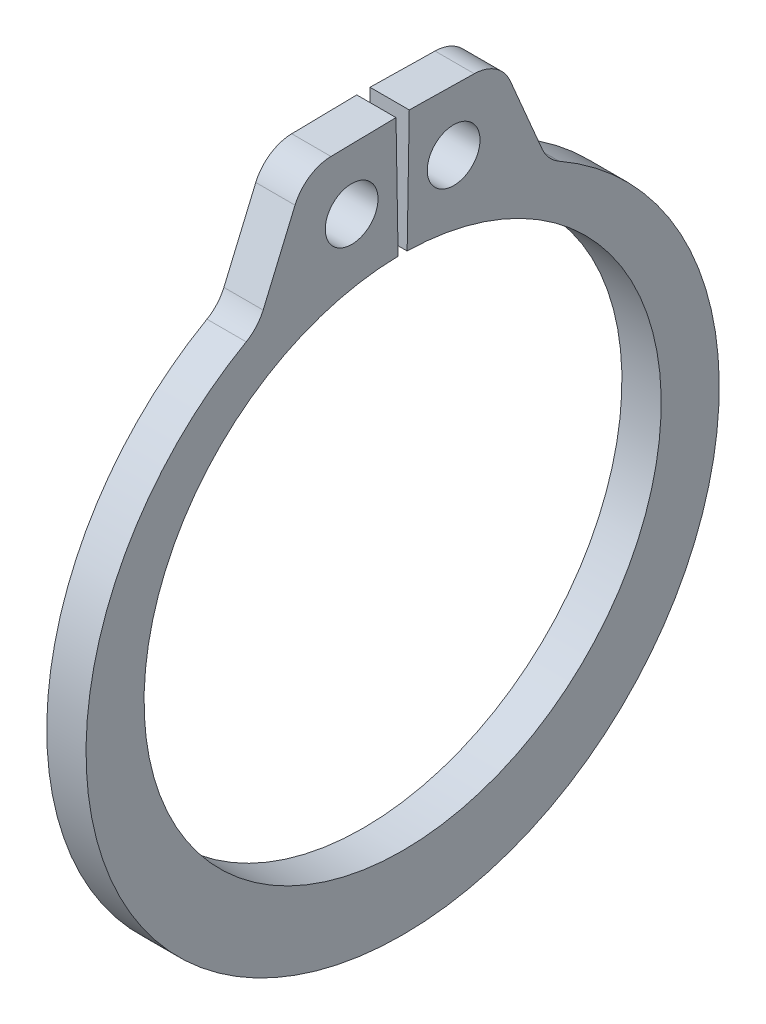
from build123d import *

# Parameters (mm, degrees)
SKETCH1_R      = 0.5969
EXTRUDE1_DEPTH = 0.4445
FILLET1_R      = 0.9017


with BuildPart() as part:
    # Sketch1 → Extrude1 (new body, symmetric)
    with BuildSketch(Plane(origin=(0, 0, 0), x_dir=(0, 0, -1), z_dir=(1, 0, 0))):
        with BuildLine():
            Line((-0.102178604, 5.853808301), (-0.150054045, 8.596590498))
            Line((-0.150054045, 8.596590498), (-2.207140693, 8.560683917))
            Line((-2.207140693, 8.560683917), (-3.281285866, 6.036528932))
            ThreePointArc((-3.281285866, 6.036528932), (0, -7.5057), (3.281285866, 6.036528932))
            Line((3.281285866, 6.036528932), (2.207140693, 8.560683917))
            Line((2.207140693, 8.560683917), (0.150054045, 8.596590498))
            Line((0.150054045, 8.596590498), (0.102178604, 5.853808301))
            ThreePointArc((0.102178604, 5.853808301), (0, -5.8547), (-0.102178604, 5.853808301))
        make_face()
        with Locations((-1.154659649, 7.207246109)):
            Circle(SKETCH1_R, mode=Mode.SUBTRACT)
        with Locations((1.154659649, 7.207246109)):
            Circle(SKETCH1_R, mode=Mode.SUBTRACT)
    extrude(amount=EXTRUDE1_DEPTH, both=True)

    # Fillet1
    fillet1_edges = [part.edges().sort_by_distance(p)[0] for p in [
        (0, 8.560683917, -2.207140693),
        (0, 6.036528932, -3.281285866),
        (0, 6.036528932, 3.281285866),
        (0, 8.560683917, 2.207140693),
    ]]
    fillet(fillet1_edges, radius=FILLET1_R)


solid = part.part
